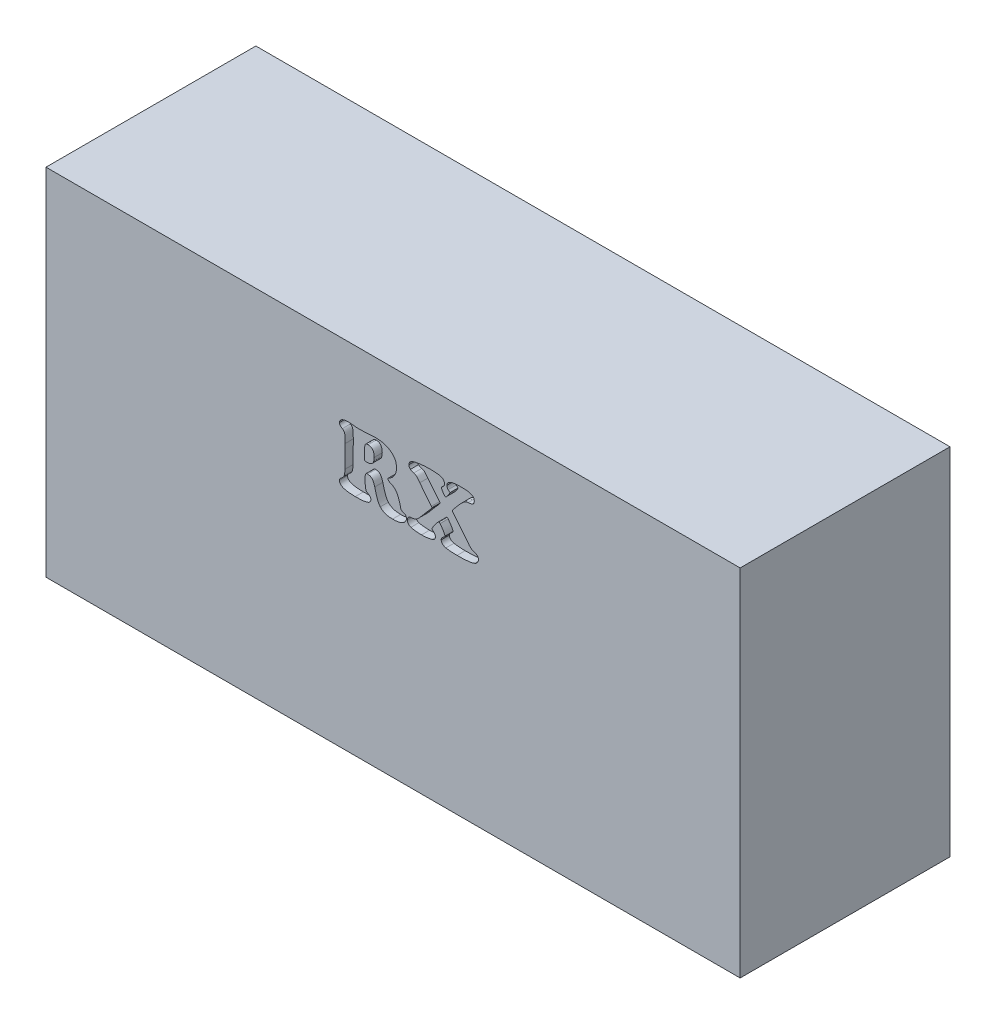
from build123d import *

# Parameters (mm, degrees)
SKICA1_W                 = 43
SKICA1_H                 = 22
P_IDAT_VYSUNUT_M1_DEPTH  = 13
ODEBRAT_VYSUNUT_M1_DEPTH = 0.5


with BuildPart() as part:
    # Skica1 → Přidat vysunutím1 (new body)
    with BuildSketch(Plane.XY):
        Rectangle(SKICA1_W, SKICA1_H)
    extrude(amount=P_IDAT_VYSUNUT_M1_DEPTH)

    # Skica2 → Odebrat vysunutím1 (cut)
    with BuildSketch(Plane.XY.offset(13)):
        with BuildLine():
            add(Edge.make_bspline(
                [(-1.572781919, 4.49421781), (-1.588608599, 4.493540747), (-1.617543428, 4.492302918), (-1.656940454, 4.481341999), (-1.687752348, 4.461780661), (-1.709226978, 4.430636779), (-1.719786113, 4.385275299), (-1.727988533, 4.323695248), (-1.733289869, 4.241782849), (-1.733575054, 4.180592882), (-1.733733056, 4.146691475)],
                knots=[0, 0, 0, 0, 4.7414e-05, 8.6683e-05, 0.000121329, 0.000154654, 0.000197222, 0.000259506, 0.000341375, 0.000443083, 0.000443083, 0.000443083, 0.000443083], degree=3))
            add(Edge.make_bspline(
                [(-1.733733056, 4.146691475), (-1.733034466, 4.093298054), (-1.731716762, 3.992585564), (-1.724299394, 3.85063852), (-1.710592094, 3.726999532), (-1.695749286, 3.651485893), (-1.688890948, 3.616593702)],
                knots=[0, 0, 0, 0, 0.000160182, 0.000302142, 0.000426297, 0.000532941, 0.000532941, 0.000532941, 0.000532941], degree=3))
            add(Edge.make_bspline(
                [(-1.688890948, 3.616593702), (-1.684127334, 3.600511281), (-1.675312966, 3.570753122), (-1.653586829, 3.537995344), (-1.629618789, 3.517112325), (-1.606051362, 3.499963972), (-1.575732208, 3.48158476), (-1.55359499, 3.468931701), (-1.541552594, 3.462048581)],
                knots=[0, 0, 0, 0, 5.0148e-05, 9.2791e-05, 0.000115468, 0.000145258, 0.000180143, 0.000221759, 0.000221759, 0.000221759, 0.000221759], degree=3))
            add(Edge.make_bspline(
                [(-1.541552594, 3.462048581), (-1.516360635, 3.447497104), (-1.469149321, 3.420226725), (-1.415435726, 3.363412764), (-1.380687731, 3.298945298), (-1.37689821, 3.25239437), (-1.374996194, 3.229029771)],
                knots=[0, 0, 0, 0, 8.6844e-05, 0.000162751, 0.000231866, 0.000301513, 0.000301513, 0.000301513, 0.000301513], degree=3))
            add(Edge.make_bspline(
                [(-1.374996194, 3.229029771), (-1.375517318, 3.214817089), (-1.376535491, 3.18704835), (-1.38732285, 3.147006906), (-1.405339221, 3.110569782), (-1.429759017, 3.076990366), (-1.461609338, 3.047437747), (-1.499822521, 3.020699236), (-1.545172981, 2.997579532), (-1.597937822, 2.977810691), (-1.658576936, 2.959850311), (-1.728679384, 2.946268776), (-1.807671832, 2.933293435), (-1.896391907, 2.923077064), (-1.994412239, 2.915200674), (-2.102307463, 2.910001943), (-2.219485575, 2.905475974), (-2.300927191, 2.905508927), (-2.34310527, 2.905525994)],
                knots=[0, 0, 0, 0, 4.2561e-05, 8.3155e-05, 0.000123264, 0.000163945, 0.000206993, 0.000252979, 0.000303477, 0.000359243, 0.00042183, 0.00049297, 0.000573273, 0.000661969, 0.000760787, 0.000868234, 0.000986012, 0.001112534, 0.001112534, 0.001112534, 0.001112534], degree=3))
            add(Edge.make_bspline(
                [(-2.34310527, 2.905525994), (-2.382609986, 2.905918633), (-2.459237712, 2.906680241), (-2.57038312, 2.910097039), (-2.673698089, 2.918424239), (-2.769278269, 2.928869425), (-2.857429638, 2.940839528), (-2.937663492, 2.958251482), (-3.010703665, 2.976702377), (-3.075758847, 2.999582357), (-3.134077672, 3.023557981), (-3.183862685, 3.052891425), (-3.226653128, 3.083832102), (-3.26235142, 3.117718096), (-3.288688834, 3.15595845), (-3.30850504, 3.196295566), (-3.320135137, 3.24014002), (-3.321646486, 3.270332959), (-3.322424873, 3.285883157)],
                knots=[0, 0, 0, 0, 0.000118522, 0.000229899, 0.000333506, 0.000429362, 0.000518372, 0.000600193, 0.000675553, 0.00074418, 0.000806951, 0.00086436, 0.000917052, 0.000965184, 0.001011169, 0.00105558, 0.001099476, 0.001146092, 0.001146092, 0.001146092, 0.001146092], degree=3))
            add(Edge.make_bspline(
                [(-3.322424873, 3.285883157), (-3.321596194, 3.30584984), (-3.32007455, 3.34251323), (-3.301579911, 3.385793067), (-3.276751733, 3.414974707), (-3.249969088, 3.440421886), (-3.214646805, 3.469729514), (-3.187976791, 3.490175578), (-3.173485015, 3.501285425)],
                knots=[0, 0, 0, 0, 5.9601e-05, 0.000109441, 0.00013733, 0.000174138, 0.000220173, 0.000274952, 0.000274952, 0.000274952, 0.000274952], degree=3))
            add(Edge.make_bspline(
                [(-3.173485015, 3.501285425), (-3.156435183, 3.514351204), (-3.123441467, 3.539635243), (-3.083373184, 3.585653009), (-3.050322818, 3.633897985), (-3.026090415, 3.689301558), (-3.008381901, 3.756226241), (-2.995013131, 3.839683106), (-2.982903598, 3.94225491), (-2.978230976, 4.017201175), (-2.97569929, 4.057808012)],
                knots=[0, 0, 0, 0, 6.4285e-05, 0.0001244, 0.000182143, 0.000239137, 0.000304804, 0.00038932, 0.000492518, 0.00061455, 0.00061455, 0.00061455, 0.00061455], degree=3))
            add(Edge.make_bspline(
                [(-2.97569929, 4.057808012), (-2.975153864, 4.067149197), (-2.973907628, 4.088492754), (-2.972111759, 4.124518151), (-2.971970378, 4.168325403), (-2.969657726, 4.219810685), (-2.969365986, 4.27908477), (-2.968414464, 4.346077334), (-2.967661675, 4.420815413), (-2.966853426, 4.503292582), (-2.966045658, 4.593777662), (-2.965310143, 4.692003488), (-2.96425829, 4.797967828), (-2.964496094, 4.911676549), (-2.964739016, 5.033392355), (-2.963382943, 5.162843905), (-2.963771318, 5.300041419), (-2.963716301, 5.393996142), (-2.963688011, 5.442308088)],
                knots=[0, 0, 0, 0, 2.8072e-05, 6.4141e-05, 0.00010819, 0.000159463, 0.000218724, 0.000285992, 0.000360466, 0.000442948, 0.000533436, 0.000631932, 0.000737634, 0.000851341, 0.000973055, 0.00110278, 0.001239708, 0.001384644, 0.001384644, 0.001384644, 0.001384644], degree=3))
            add(Edge.make_bspline(
                [(-2.963688011, 5.442308088), (-2.963882893, 5.472470791), (-2.964257163, 5.530397904), (-2.965936081, 5.613411296), (-2.967984996, 5.688985236), (-2.972109919, 5.756784366), (-2.976918547, 5.817115332), (-2.982113324, 5.870081105), (-2.98934816, 5.915475013), (-2.999459431, 5.964984551), (-3.017303156, 6.018419543), (-3.048650643, 6.074275169), (-3.091253269, 6.120305538), (-3.125713973, 6.142837341), (-3.143056442, 6.154176548)],
                knots=[0, 0, 0, 0, 9.0489e-05, 0.000173782, 0.000249091, 0.000317273, 0.000377521, 0.000430667, 0.000476875, 0.000515353, 0.000582205, 0.000644976, 0.000706169, 0.000768164, 0.000768164, 0.000768164, 0.000768164], degree=3))
            add(Edge.make_bspline(
                [(-3.143056442, 6.154176548), (-3.159462519, 6.163309752), (-3.189844001, 6.180223014), (-3.230396045, 6.20678317), (-3.262533308, 6.231758562), (-3.294010195, 6.264410017), (-3.318574436, 6.315232822), (-3.321091256, 6.359130355), (-3.322424873, 6.382390847)],
                knots=[0, 0, 0, 0, 5.6315e-05, 0.000104287, 0.000145305, 0.000178165, 0.000239761, 0.000309187, 0.000309187, 0.000309187, 0.000309187], degree=3))
            add(Edge.make_bspline(
                [(-3.322424873, 6.382390847), (-3.321546543, 6.398789984), (-3.319811662, 6.431181643), (-3.30459675, 6.477457004), (-3.280696747, 6.520648908), (-3.246554827, 6.559367766), (-3.20459378, 6.59491422), (-3.154559422, 6.625216946), (-3.09706405, 6.650122544), (-3.05566679, 6.662057258), (-3.03415418, 6.668259284)],
                knots=[0, 0, 0, 0, 4.9082e-05, 9.6946e-05, 0.000144623, 0.000196301, 0.000250846, 0.000309076, 0.000371112, 0.000438227, 0.000438227, 0.000438227, 0.000438227], degree=3))
            add(Edge.make_bspline(
                [(-3.03415418, 6.668259284), (-3.013121714, 6.672832128), (-2.967879799, 6.682668552), (-2.893974255, 6.691734924), (-2.809765609, 6.697298277), (-2.750164784, 6.697683476), (-2.718657922, 6.697887105)],
                knots=[0, 0, 0, 0, 6.4544e-05, 0.000138837, 0.000223103, 0.000317605, 0.000317605, 0.000317605, 0.000317605], degree=3))
            add(Edge.make_bspline(
                [(-2.718657922, 6.697887105), (-2.709849012, 6.69764209), (-2.689554689, 6.697077616), (-2.65483034, 6.695514252), (-2.61211688, 6.692217974), (-2.561137182, 6.687325614), (-2.501941206, 6.680617548), (-2.434331859, 6.67386223), (-2.35861032, 6.664579864), (-2.305475459, 6.658601304), (-2.277443612, 6.655447253)],
                knots=[0, 0, 0, 0, 2.6437e-05, 6.0907e-05, 0.000104266, 0.000154941, 0.000214542, 0.000282987, 0.000358771, 0.000443397, 0.000443397, 0.000443397, 0.000443397], degree=3))
            add(Edge.make_bspline(
                [(-2.277443612, 6.655447253), (-2.264643709, 6.653961393), (-2.23591015, 6.650625898), (-2.187767471, 6.648880131), (-2.130118656, 6.647147599), (-2.08846873, 6.646816981), (-2.066045104, 6.646638982)],
                knots=[0, 0, 0, 0, 3.8644e-05, 8.6749e-05, 0.000144426, 0.000211693, 0.000211693, 0.000211693, 0.000211693], degree=3))
            add(Edge.make_bspline(
                [(-2.066045104, 6.646638982), (-2.02253452, 6.64729049), (-1.929080381, 6.648689831), (-1.778740937, 6.654266235), (-1.608489259, 6.665270252), (-1.488162008, 6.674039753), (-1.424642813, 6.678669059)],
                knots=[0, 0, 0, 0, 0.000130545, 0.00028039, 0.000451268, 0.000642332, 0.000642332, 0.000642332, 0.000642332], degree=3))
            add(Edge.make_bspline(
                [(-1.424642813, 6.678669059), (-1.385419424, 6.681823935), (-1.313415009, 6.687615506), (-1.214849062, 6.692506407), (-1.135620612, 6.697562105), (-1.089133151, 6.697789259), (-1.069108959, 6.697887105)],
                knots=[0, 0, 0, 0, 0.00011804, 0.000216691, 0.000296067, 0.000356129, 0.000356129, 0.000356129, 0.000356129], degree=3))
            add(Edge.make_bspline(
                [(-1.069108959, 6.697887105), (-1.022358419, 6.697307779), (-0.93078224, 6.696172979), (-0.79681654, 6.681722157), (-0.669045298, 6.660674526), (-0.547451317, 6.630120263), (-0.432132382, 6.590779078), (-0.322390224, 6.54377003), (-0.21942755, 6.486630853), (-0.155367287, 6.442188993), (-0.123420937, 6.420026187)],
                knots=[0, 0, 0, 0, 0.000140189, 0.000274605, 0.000403748, 0.000528431, 0.000650232, 0.000768941, 0.000886149, 0.001002746, 0.001002746, 0.001002746, 0.001002746], degree=3))
            add(Edge.make_bspline(
                [(-0.123420937, 6.420026187), (-0.096382229, 6.398823417), (-0.043305051, 6.357202228), (0.024941988, 6.283681429), (0.083977095, 6.205448186), (0.131414878, 6.120411383), (0.168794573, 6.02963532), (0.195071147, 5.932539107), (0.210224339, 5.829279493), (0.212521801, 5.758654853), (0.213695623, 5.722571262)],
                knots=[0, 0, 0, 0, 0.000102936, 0.000202065, 0.000299917, 0.00039636, 0.000493314, 0.000593744, 0.000697363, 0.00080561, 0.00080561, 0.00080561, 0.00080561], degree=3))
            add(Edge.make_bspline(
                [(0.213695623, 5.722571262), (0.21243883, 5.681890205), (0.209971214, 5.60201603), (0.18659304, 5.485078707), (0.148760526, 5.373959551), (0.096983349, 5.269346658), (0.032174638, 5.173804951), (-0.044480597, 5.089774048), (-0.132447886, 5.017758781), (-0.198840792, 4.981662197), (-0.232323199, 4.963458438)],
                knots=[0, 0, 0, 0, 0.000121927, 0.000239395, 0.000356132, 0.000473234, 0.000588503, 0.000701296, 0.000813472, 0.000927598, 0.000927598, 0.000927598, 0.000927598], degree=3))
            add(Edge.make_bspline(
                [(-0.232323199, 4.963458438), (-0.245210792, 4.956489619), (-0.268937127, 4.943659873), (-0.29693698, 4.918814526), (-0.31527893, 4.890999309), (-0.317649335, 4.870803423), (-0.318804407, 4.860962192)],
                knots=[0, 0, 0, 0, 4.3808e-05, 8.0651e-05, 0.00011155, 0.000140917, 0.000140917, 0.000140917, 0.000140917], degree=3))
            add(Edge.make_bspline(
                [(-0.318804407, 4.860962192), (-0.317307522, 4.847939216), (-0.314209448, 4.820985807), (-0.284577291, 4.787030779), (-0.243803695, 4.755795715), (-0.208581244, 4.742051815), (-0.189082595, 4.734443388)],
                knots=[0, 0, 0, 0, 3.8478e-05, 7.9637e-05, 0.000129925, 0.000192286, 0.000192286, 0.000192286, 0.000192286], degree=3))
            add(Edge.make_bspline(
                [(-0.189082595, 4.734443388), (-0.145479525, 4.716225681), (-0.061165474, 4.680998606), (0.051282674, 4.609032346), (0.145778077, 4.52401873), (0.221057556, 4.422292255), (0.283880102, 4.303748673), (0.341868984, 4.166102359), (0.396214667, 4.006625008), (0.426138602, 3.891743284), (0.441909921, 3.831195218)],
                knots=[0, 0, 0, 0, 0.000141554, 0.00027372, 0.000398416, 0.000520771, 0.000651205, 0.000800089, 0.000968485, 0.001156142, 0.001156142, 0.001156142, 0.001156142], degree=3))
            add(Edge.make_bspline(
                [(0.441909921, 3.831195218), (0.445798622, 3.805780473), (0.452849494, 3.759699252), (0.467589547, 3.69768654), (0.485460275, 3.650630334), (0.506370199, 3.613045139), (0.540841806, 3.588082465), (0.584680655, 3.56385323), (0.643786077, 3.541529193), (0.688195687, 3.527952988), (0.712564071, 3.520503471)],
                knots=[0, 0, 0, 0, 7.7143e-05, 0.000139873, 0.00019058, 0.000228352, 0.000266495, 0.00031596, 0.000378859, 0.000455338, 0.000455338, 0.000455338, 0.000455338], degree=3))
            add(Edge.make_bspline(
                [(0.712564071, 3.520503471), (0.72835024, 3.511876981), (0.762396555, 3.493272075), (0.797712911, 3.44218925), (0.825036637, 3.381053225), (0.827441309, 3.335064768), (0.8286731, 3.311507219)],
                knots=[0, 0, 0, 0, 5.3309e-05, 0.000114972, 0.000181742, 0.000251866, 0.000251866, 0.000251866, 0.000251866], degree=3))
            add(Edge.make_bspline(
                [(0.8286731, 3.311507219), (0.827906417, 3.295679978), (0.82636403, 3.263839247), (0.813294487, 3.216007447), (0.792567647, 3.168258185), (0.763433974, 3.12176043), (0.729642685, 3.076714755), (0.689153031, 3.037090477), (0.644886273, 3.000761047), (0.611707592, 2.981680771), (0.594853538, 2.971988403)],
                knots=[0, 0, 0, 0, 4.7414e-05, 9.5385e-05, 0.000147747, 0.000203092, 0.000259629, 0.000316251, 0.000372651, 0.000430881, 0.000430881, 0.000430881, 0.000430881], degree=3))
            add(Edge.make_bspline(
                [(0.594853538, 2.971988403), (0.574964736, 2.962605957), (0.534213726, 2.943381864), (0.46877262, 2.919677075), (0.398388461, 2.898398487), (0.322118438, 2.883144056), (0.240923043, 2.870198151), (0.154628615, 2.860639542), (0.062965353, 2.854956008), (0.000170222, 2.854508232), (-0.032135218, 2.85427787)],
                knots=[0, 0, 0, 0, 6.5939e-05, 0.000135106, 0.000208583, 0.000286322, 0.000368207, 0.00045522, 0.000546678, 0.000643582, 0.000643582, 0.000643582, 0.000643582], degree=3))
            add(Edge.make_bspline(
                [(-0.032135218, 2.85427787), (-0.074893594, 2.854797646), (-0.157444107, 2.855801138), (-0.276143794, 2.870447472), (-0.386145523, 2.890103042), (-0.486089024, 2.920795694), (-0.577523587, 2.958905988), (-0.658116182, 3.007873816), (-0.732257226, 3.062231616), (-0.772215739, 3.107344935), (-0.792048794, 3.129736532)],
                knots=[0, 0, 0, 0, 0.000128183, 0.000247473, 0.000358348, 0.000462965, 0.000560538, 0.000654609, 0.000745419, 0.00083491, 0.00083491, 0.00083491, 0.00083491], degree=3))
            add(Edge.make_bspline(
                [(-0.792048794, 3.129736532), (-0.809052776, 3.151303385), (-0.843958212, 3.19557539), (-0.888989589, 3.270218649), (-0.931852412, 3.351681326), (-0.962732176, 3.426686501), (-0.986581787, 3.492570883), (-1.006073482, 3.549081561), (-1.025833814, 3.612170612), (-1.046655839, 3.681842165), (-1.068211047, 3.757938625), (-1.090742109, 3.840659333), (-1.113704726, 3.929881702), (-1.129197886, 3.99160439), (-1.137172873, 4.023375679)],
                knots=[0, 0, 0, 0, 8.2318e-05, 0.000168981, 0.000261025, 0.000358286, 0.00041199, 0.000471246, 0.000537597, 0.000610307, 0.000689391, 0.000774862, 0.000867504, 0.000965775, 0.000965775, 0.000965775, 0.000965775], degree=3))
            add(Edge.make_bspline(
                [(-1.137172873, 4.023375679), (-1.147668836, 4.062832657), (-1.167204719, 4.136272976), (-1.204846826, 4.235608765), (-1.245765624, 4.31711586), (-1.293054181, 4.381643627), (-1.349124736, 4.430341311), (-1.414505695, 4.465129999), (-1.490368, 4.486914269), (-1.544341779, 4.491697438), (-1.572781919, 4.49421781)],
                knots=[0, 0, 0, 0, 0.000122421, 0.000227859, 0.000318113, 0.000395306, 0.000466266, 0.000538994, 0.00061577, 0.000701286, 0.000701286, 0.000701286, 0.000701286], degree=3))
        make_face()
        with BuildLine():
            Line((-1.754552606, 5.874714127), (-1.784981179, 5.284559959))
            add(Edge.make_bspline(
                [(-1.784981179, 5.284559959), (-1.784981179, 5.281356952), (-1.784981179, 5.27361635), (-1.784981179, 5.265875748), (-1.784981179, 5.261338153)],
                knots=[0, 0, 0, 0, 9.609e-06, 2.3222e-05, 2.3222e-05, 2.3222e-05, 2.3222e-05], degree=3))
            add(Edge.make_bspline(
                [(-1.784981179, 5.261338153), (-1.784818916, 5.247430515), (-1.784520807, 5.221879549), (-1.778982836, 5.187417857), (-1.770732899, 5.159837072), (-1.757283306, 5.138693451), (-1.736869313, 5.123830458), (-1.709508569, 5.116531991), (-1.676190395, 5.109176288), (-1.651319678, 5.109188547), (-1.637642825, 5.109195288)],
                knots=[0, 0, 0, 0, 4.167e-05, 7.6555e-05, 0.00010441, 0.000127507, 0.000150409, 0.000178263, 0.000211713, 0.000252583, 0.000252583, 0.000252583, 0.000252583], degree=3))
            add(Edge.make_bspline(
                [(-1.637642825, 5.109195288), (-1.599350001, 5.110338381), (-1.527924247, 5.112470537), (-1.4287725, 5.134064682), (-1.345578659, 5.169672202), (-1.278267664, 5.222010447), (-1.228025246, 5.291529827), (-1.19400846, 5.377585732), (-1.173532791, 5.480060028), (-1.171234342, 5.554039791), (-1.170003702, 5.593650202)],
                knots=[0, 0, 0, 0, 0.000114734, 0.000214008, 0.000302548, 0.000384087, 0.000466569, 0.000556684, 0.000659705, 0.000778435, 0.000778435, 0.000778435, 0.000778435], degree=3))
            add(Edge.make_bspline(
                [(-1.170003702, 5.593650202), (-1.170759382, 5.631915277), (-1.172180716, 5.703886852), (-1.190881475, 5.80417436), (-1.219685986, 5.89009267), (-1.261772602, 5.961141447), (-1.316948561, 6.016746121), (-1.384555501, 6.056020244), (-1.464344065, 6.078673415), (-1.521113865, 6.081443465), (-1.551161617, 6.082909627)],
                knots=[0, 0, 0, 0, 0.000114645, 0.000215631, 0.000304778, 0.000385252, 0.000461126, 0.00053721, 0.000617285, 0.000707326, 0.000707326, 0.000707326, 0.000707326], degree=3))
            add(Edge.make_bspline(
                [(-1.551161617, 6.082909627), (-1.567998079, 6.082221307), (-1.599219497, 6.08094489), (-1.64257547, 6.073688313), (-1.677892302, 6.059226987), (-1.706423907, 6.03861629), (-1.726056625, 6.008811442), (-1.74154712, 5.972058109), (-1.750092648, 5.926008441), (-1.752995732, 5.892619848), (-1.754552606, 5.874714127)],
                knots=[0, 0, 0, 0, 5.0549e-05, 9.3738e-05, 0.000131065, 0.000164217, 0.000197542, 0.000236656, 0.000283299, 0.000337242, 0.000337242, 0.000337242, 0.000337242], degree=3))
        make_face(mode=Mode.SUBTRACT)
        with BuildLine():
            Line((3.701771003, 5.097984761), (4.726733465, 3.815980931))
            add(Edge.make_bspline(
                [(4.726733465, 3.815980931), (4.741016159, 3.800905639), (4.767504809, 3.772947038), (4.806143723, 3.735973845), (4.83940264, 3.706453329), (4.878631726, 3.675030378), (4.937661149, 3.646833964), (4.988330415, 3.631536336), (5.016605662, 3.622999717)],
                knots=[0, 0, 0, 0, 6.2294e-05, 0.000115531, 0.000160351, 0.000195748, 0.00026594, 0.000354567, 0.000354567, 0.000354567, 0.000354567], degree=3))
            add(Edge.make_bspline(
                [(5.016605662, 3.622999717), (5.039655012, 3.614455931), (5.082854953, 3.598442853), (5.141877498, 3.572150816), (5.188992914, 3.542076033), (5.226654119, 3.510728425), (5.254066996, 3.474706922), (5.273902926, 3.43461485), (5.2850099, 3.388695381), (5.286487541, 3.356408078), (5.287259812, 3.339533536)],
                knots=[0, 0, 0, 0, 7.3761e-05, 0.000138245, 0.000193334, 0.000241017, 0.000284421, 0.000328111, 0.000374333, 0.000424939, 0.000424939, 0.000424939, 0.000424939], degree=3))
            add(Edge.make_bspline(
                [(5.287259812, 3.339533536), (5.286581583, 3.322894836), (5.285236796, 3.289903731), (5.271437375, 3.241408088), (5.249533924, 3.194842227), (5.220033122, 3.150405943), (5.184140297, 3.109777125), (5.143251981, 3.074418551), (5.097379099, 3.044789378), (5.064076781, 3.030002829), (5.047034235, 3.022435774)],
                knots=[0, 0, 0, 0, 4.9808e-05, 9.8759e-05, 0.000149988, 0.000203734, 0.000258197, 0.000312133, 0.000365442, 0.000421317, 0.000421317, 0.000421317, 0.000421317], degree=3))
            add(Edge.make_bspline(
                [(5.047034235, 3.022435774), (5.01835906, 3.012070486), (4.958552846, 2.990452181), (4.861597072, 2.966550072), (4.755106161, 2.945298758), (4.635726602, 2.930462891), (4.499716503, 2.919691598), (4.342479202, 2.910648053), (4.161692832, 2.906409096), (4.033283653, 2.90583193), (3.965218386, 2.905525994)],
                knots=[0, 0, 0, 0, 9.1416e-05, 0.00019066, 0.000299176, 0.000417072, 0.000551267, 0.000708461, 0.000889495, 0.001093693, 0.001093693, 0.001093693, 0.001093693], degree=3))
            add(Edge.make_bspline(
                [(3.965218386, 2.905525994), (3.927850093, 2.90569844), (3.855774319, 2.906031055), (3.751094107, 2.908045408), (3.65397394, 2.913412012), (3.563643125, 2.918270664), (3.480962944, 2.926791306), (3.405001913, 2.93507309), (3.336584436, 2.946076266), (3.293617951, 2.955524408), (3.273368723, 2.959977124)],
                knots=[0, 0, 0, 0, 0.000112108, 0.000216234, 0.000314043, 0.000403903, 0.000487565, 0.000563349, 0.00063312, 0.000695312, 0.000695312, 0.000695312, 0.000695312], degree=3))
            add(Edge.make_bspline(
                [(3.273368723, 2.959977124), (3.251846984, 2.96616449), (3.210432156, 2.978070994), (3.152848946, 3.003263598), (3.101890283, 3.033236888), (3.059409846, 3.069718642), (3.024378318, 3.109152562), (3.000191125, 3.152757195), (2.983552031, 3.198216234), (2.981914303, 3.229954036), (2.981094271, 3.245845561)],
                knots=[0, 0, 0, 0, 6.7115e-05, 0.000129152, 0.000188065, 0.000243739, 0.000296546, 0.000345313, 0.000392666, 0.000440154, 0.000440154, 0.000440154, 0.000440154], degree=3))
            add(Edge.make_bspline(
                [(2.981094271, 3.245845561), (2.982368969, 3.265566853), (2.984902122, 3.304758129), (3.0087755, 3.359426273), (3.046481107, 3.408228153), (3.080177429, 3.43295311), (3.098004052, 3.446033542)],
                knots=[0, 0, 0, 0, 5.8897e-05, 0.000117044, 0.000175827, 0.000241859, 0.000241859, 0.000241859, 0.000241859], degree=3))
            add(Edge.make_bspline(
                [(3.098004052, 3.446033542), (3.115109084, 3.457464353), (3.145638228, 3.47786612), (3.182034861, 3.508538464), (3.207608288, 3.534651624), (3.212227489, 3.553604938), (3.214113081, 3.561341819)],
                knots=[0, 0, 0, 0, 6.1533e-05, 0.000109824, 0.000143967, 0.000167518, 0.000167518, 0.000167518, 0.000167518], degree=3))
            add(Edge.make_bspline(
                [(3.214113081, 3.561341819), (3.212857435, 3.572356773), (3.209915147, 3.598167521), (3.194905931, 3.640966814), (3.170394602, 3.69241944), (3.137033481, 3.753792311), (3.094599454, 3.824418544), (3.043403493, 3.904947456), (2.980928271, 3.993478449), (2.936536977, 4.05595434), (2.913030358, 4.089037337)],
                knots=[0, 0, 0, 0, 3.3181e-05, 7.775e-05, 0.000135075, 0.000204223, 0.00028717, 0.00038224, 0.000490416, 0.000612172, 0.000612172, 0.000612172, 0.000612172], degree=3))
            add(Edge.make_bspline(
                [(2.913030358, 4.089037337), (2.907119088, 4.096733119), (2.896357452, 4.110743512), (2.878724655, 4.126718399), (2.862400798, 4.137981515), (2.850963188, 4.139565756), (2.845767196, 4.14028546)],
                knots=[0, 0, 0, 0, 2.9016e-05, 5.2824e-05, 7.15e-05, 8.7048e-05, 8.7048e-05, 8.7048e-05, 8.7048e-05], degree=3))
            add(Edge.make_bspline(
                [(2.845767196, 4.14028546), (2.83459974, 4.137360322), (2.807211814, 4.130186491), (2.788679202, 4.108366323), (2.777703283, 4.095443352)],
                knots=[0, 0, 0, 0, 3.3935e-05, 8.3225e-05, 8.3225e-05, 8.3225e-05, 8.3225e-05], degree=3))
            add(Edge.make_bspline(
                [(2.777703283, 4.095443352), (2.732317165, 4.042428667), (2.643643776, 3.938850921), (2.547262775, 3.804262931), (2.482292124, 3.705030711), (2.449267836, 3.645466914), (2.425081894, 3.601453843), (2.420669932, 3.574826114), (2.418966421, 3.564544827)],
                knots=[0, 0, 0, 0, 0.000209255, 0.000408834, 0.000496351, 0.000564485, 0.000613925, 0.00064502, 0.00064502, 0.00064502, 0.00064502], degree=3))
            add(Edge.make_bspline(
                [(2.418966421, 3.564544827), (2.420558121, 3.556042387), (2.424300878, 3.536049563), (2.447255303, 3.506888262), (2.479315952, 3.472256271), (2.50697001, 3.449184052), (2.522263419, 3.436424519)],
                knots=[0, 0, 0, 0, 2.5637e-05, 6.0282e-05, 0.000108441, 0.000168026, 0.000168026, 0.000168026, 0.000168026], degree=3))
            add(Edge.make_bspline(
                [(2.522263419, 3.436424519), (2.537642421, 3.422923362), (2.567261645, 3.396920778), (2.599486898, 3.347968633), (2.618780387, 3.293418463), (2.621145573, 3.255079363), (2.622357409, 3.235435786)],
                knots=[0, 0, 0, 0, 6.1162e-05, 0.000117795, 0.000173762, 0.000232567, 0.000232567, 0.000232567, 0.000232567], degree=3))
            add(Edge.make_bspline(
                [(2.622357409, 3.235435786), (2.621764338, 3.220971841), (2.620608076, 3.192772678), (2.610893846, 3.151916348), (2.593975051, 3.115154466), (2.570868555, 3.081822788), (2.540569805, 3.05305748), (2.504272182, 3.027285772), (2.461335506, 3.005513064), (2.429806119, 2.995058035), (2.413361157, 2.989604946)],
                knots=[0, 0, 0, 0, 4.3359e-05, 8.4534e-05, 0.000125025, 0.000164123, 0.00020546, 0.000249676, 0.000297306, 0.000349231, 0.000349231, 0.000349231, 0.000349231], degree=3))
            add(Edge.make_bspline(
                [(2.413361157, 2.989604946), (2.365775584, 2.976487793), (2.267268466, 2.949333914), (2.110103726, 2.923859331), (1.940148706, 2.908878478), (1.822439924, 2.906668972), (1.761549091, 2.905525994)],
                knots=[0, 0, 0, 0, 0.000147992, 0.000306359, 0.000476798, 0.000659456, 0.000659456, 0.000659456, 0.000659456], degree=3))
            add(Edge.make_bspline(
                [(1.761549091, 2.905525994), (1.726843582, 2.905508488), (1.659541909, 2.90547454), (1.561586188, 2.910100286), (1.469964855, 2.915214704), (1.384478757, 2.923171673), (1.305249818, 2.933897635), (1.231791472, 2.945033595), (1.164874012, 2.960649993), (1.122772475, 2.972633031), (1.102530258, 2.978394419)],
                knots=[0, 0, 0, 0, 0.000104101, 0.000201875, 0.000294131, 0.000379388, 0.000459343, 0.000533985, 0.000602167, 0.000665304, 0.000665304, 0.000665304, 0.000665304], degree=3))
            add(Edge.make_bspline(
                [(1.102530258, 2.978394419), (1.087367423, 2.984069756), (1.057041754, 2.995420429), (1.015454353, 3.020780284), (0.976906188, 3.051708265), (0.943158721, 3.088719724), (0.915680102, 3.129642512), (0.894852558, 3.172038502), (0.882288004, 3.215768834), (0.880706275, 3.245501852), (0.879921223, 3.260259096)],
                knots=[0, 0, 0, 0, 4.8477e-05, 9.6954e-05, 0.000145351, 0.000196361, 0.000246554, 0.000292755, 0.000337633, 0.000381856, 0.000381856, 0.000381856, 0.000381856], degree=3))
            add(Edge.make_bspline(
                [(0.879921223, 3.260259096), (0.8807075, 3.279056512), (0.882230209, 3.315459677), (0.897819732, 3.366665623), (0.923245555, 3.411357698), (0.958808402, 3.448889017), (1.003618231, 3.479851761), (1.057854019, 3.501538202), (1.120194113, 3.516434962), (1.164625641, 3.519092697), (1.188210714, 3.520503471)],
                knots=[0, 0, 0, 0, 5.6258e-05, 0.00010895, 0.000158809, 0.000209231, 0.000262762, 0.000320909, 0.000383449, 0.000454206, 0.000454206, 0.000454206, 0.000454206], degree=3))
            add(Edge.make_bspline(
                [(1.188210714, 3.520503471), (1.217153524, 3.522574469), (1.273319258, 3.5265934), (1.353824107, 3.546833754), (1.427027262, 3.579385579), (1.483480349, 3.616873841), (1.528875274, 3.655095676), (1.568268908, 3.693508797), (1.613345108, 3.74053149), (1.664843558, 3.795845553), (1.721514115, 3.860319676), (1.784869225, 3.932659409), (1.852758802, 4.014945895), (1.900087344, 4.072482646), (1.924902484, 4.10265012)],
                knots=[0, 0, 0, 0, 8.6929e-05, 0.000168692, 0.000247557, 0.000326177, 0.000371084, 0.000425452, 0.000491143, 0.000566503, 0.000652154, 0.00074865, 0.000854969, 0.000972159, 0.000972159, 0.000972159, 0.000972159], degree=3))
            Line((1.924902484, 4.10265012), (2.375725817, 4.619935862))
            add(Edge.make_bspline(
                [(2.375725817, 4.619935862), (2.386401969, 4.631784897), (2.403991587, 4.651306913), (2.410717563, 4.676497358), (2.413361157, 4.686398272)],
                knots=[0, 0, 0, 0, 4.6924e-05, 7.7311e-05, 7.7311e-05, 7.7311e-05, 7.7311e-05], degree=3))
            add(Edge.make_bspline(
                [(2.413361157, 4.686398272), (2.4107877, 4.694340045), (2.403418371, 4.717082038), (2.387128091, 4.734875131), (2.376526569, 4.746454666)],
                knots=[0, 0, 0, 0, 2.4836e-05, 7.1121e-05, 7.1121e-05, 7.1121e-05, 7.1121e-05], degree=3))
            Line((2.376526569, 4.746454666), (1.655049085, 5.644097573))
            add(Edge.make_bspline(
                [(1.655049085, 5.644097573), (1.642191805, 5.66061106), (1.617757024, 5.691994324), (1.583523588, 5.737411156), (1.551508623, 5.776771238), (1.523813766, 5.811710748), (1.498235291, 5.840205225), (1.478141387, 5.865600239), (1.459764858, 5.884429397), (1.439788447, 5.903552533), (1.413804793, 5.923929906), (1.376372427, 5.944441508), (1.331351512, 5.963321424), (1.298525081, 5.974486161), (1.281097937, 5.980413381)],
                knots=[0, 0, 0, 0, 6.2786e-05, 0.000119323, 0.000170596, 0.000214993, 0.000253035, 0.000285433, 0.000312051, 0.000331877, 0.000368397, 0.000410708, 0.000459495, 0.000514706, 0.000514706, 0.000514706, 0.000514706], degree=3))
            add(Edge.make_bspline(
                [(1.281097937, 5.980413381), (1.256637021, 5.988258307), (1.211761946, 6.002650314), (1.153301773, 6.028027702), (1.106540948, 6.048976815), (1.083083307, 6.067055683), (1.072902437, 6.074902108)],
                knots=[0, 0, 0, 0, 7.6981e-05, 0.000141226, 0.000191361, 0.000229805, 0.000229805, 0.000229805, 0.000229805], degree=3))
            add(Edge.make_bspline(
                [(1.072902437, 6.074902108), (1.05924284, 6.089107538), (1.032607905, 6.116806796), (1.002946296, 6.165893781), (0.985614355, 6.219764965), (0.983488624, 6.257085201), (0.982417469, 6.275890841)],
                knots=[0, 0, 0, 0, 5.8984e-05, 0.000115014, 0.000170475, 0.000226807, 0.000226807, 0.000226807, 0.000226807], degree=3))
            add(Edge.make_bspline(
                [(0.982417469, 6.275890841), (0.983269345, 6.296344716), (0.984933034, 6.336290549), (1.004668516, 6.392729789), (1.034769241, 6.443776717), (1.07778685, 6.488421102), (1.132556667, 6.526991505), (1.19916372, 6.559542479), (1.277436079, 6.586763451), (1.334315699, 6.599218328), (1.364376137, 6.605800633)],
                knots=[0, 0, 0, 0, 6.1115e-05, 0.000119355, 0.000177171, 0.00023778, 0.000303777, 0.000377189, 0.000459495, 0.000551749, 0.000551749, 0.000551749, 0.000551749], degree=3))
            add(Edge.make_bspline(
                [(1.364376137, 6.605800633), (1.433621313, 6.620045963), (1.575661713, 6.649266949), (1.797265872, 6.676767348), (2.031620572, 6.695177573), (2.192314643, 6.696967815), (2.274831075, 6.697887105)],
                knots=[0, 0, 0, 0, 0.00021201, 0.00043489, 0.000669372, 0.000916868, 0.000916868, 0.000916868, 0.000916868], degree=3))
            add(Edge.make_bspline(
                [(2.274831075, 6.697887105), (2.317542287, 6.697901144), (2.399516351, 6.697928089), (2.517238581, 6.6935054), (2.624280839, 6.687947848), (2.720540492, 6.681523273), (2.805666764, 6.670709571), (2.880287565, 6.659066271), (2.944512092, 6.645483661), (2.98278678, 6.632544758), (3.000312317, 6.626620184)],
                knots=[0, 0, 0, 0, 0.000128123, 0.000245901, 0.000353348, 0.000449709, 0.000535224, 0.000610657, 0.000676318, 0.000731779, 0.000731779, 0.000731779, 0.000731779], degree=3))
            add(Edge.make_bspline(
                [(3.000312317, 6.626620184), (3.013909026, 6.621236663), (3.040622365, 6.610659704), (3.076369134, 6.586283087), (3.108827671, 6.557729972), (3.135485778, 6.522983077), (3.158061052, 6.485836041), (3.174359708, 6.44588833), (3.184206959, 6.404222772), (3.185461009, 6.375769229), (3.186086764, 6.361571297)],
                knots=[0, 0, 0, 0, 4.3742e-05, 8.5939e-05, 0.000129031, 0.000172927, 0.000216735, 0.000259114, 0.000301848, 0.000344408, 0.000344408, 0.000344408, 0.000344408], degree=3))
            add(Edge.make_bspline(
                [(3.186086764, 6.361571297), (3.184945131, 6.340049998), (3.182757247, 6.298805483), (3.163565125, 6.241252882), (3.132976043, 6.190751474), (3.102853836, 6.166474819), (3.087594277, 6.154176548)],
                knots=[0, 0, 0, 0, 6.438e-05, 0.00012338, 0.000180251, 0.00023864, 0.00023864, 0.00023864, 0.00023864], degree=3))
            add(Edge.make_bspline(
                [(3.087594277, 6.154176548), (3.078544964, 6.147472347), (3.062290706, 6.135430349), (3.040377633, 6.119844163), (3.025332359, 6.107064458), (3.012673364, 6.095445777), (3.003815349, 6.078080431), (3.003113631, 6.063292819), (3.002714573, 6.05488331)],
                knots=[0, 0, 0, 0, 3.3793e-05, 6.0699e-05, 8.0589e-05, 9.3046e-05, 0.000112029, 0.000137058, 0.000137058, 0.000137058, 0.000137058], degree=3))
            add(Edge.make_bspline(
                [(3.002714573, 6.05488331), (3.004407, 6.043019998), (3.008495871, 6.01435847), (3.029557567, 5.967097388), (3.059489572, 5.907109939), (3.100795268, 5.841274598), (3.142569857, 5.777220398), (3.183154181, 5.729528922), (3.215073592, 5.694909193), (3.239123148, 5.688318723), (3.248545414, 5.685736673)],
                knots=[0, 0, 0, 0, 3.5811e-05, 8.6518e-05, 0.000153843, 0.000237202, 0.000319602, 0.000382142, 0.000426963, 0.000455835, 0.000455835, 0.000455835, 0.000455835], degree=3))
            add(Edge.make_bspline(
                [(3.248545414, 5.685736673), (3.257648451, 5.688694266), (3.281672709, 5.69649979), (3.315643099, 5.731698214), (3.359395535, 5.782514729), (3.407417134, 5.849141729), (3.454335466, 5.916442305), (3.489709093, 5.974079213), (3.514196799, 6.01409702), (3.520266995, 6.037160311), (3.522402572, 6.045274287)],
                knots=[0, 0, 0, 0, 2.8401e-05, 7.4955e-05, 0.000142528, 0.000231252, 0.000320539, 0.000388527, 0.000434735, 0.000459816, 0.000459816, 0.000459816, 0.000459816], degree=3))
            add(Edge.make_bspline(
                [(3.522402572, 6.045274287), (3.521957786, 6.050886051), (3.521080136, 6.061959177), (3.509319889, 6.073324474), (3.494461256, 6.084120608), (3.475493857, 6.101739293), (3.447304835, 6.12628431), (3.425753829, 6.145597607), (3.41350031, 6.156578804)],
                knots=[0, 0, 0, 0, 1.6332e-05, 3.2227e-05, 4.6484e-05, 7.202e-05, 0.000109459, 0.000158801, 0.000158801, 0.000158801, 0.000158801], degree=3))
            add(Edge.make_bspline(
                [(3.41350031, 6.156578804), (3.402200206, 6.168382021), (3.379374185, 6.192224321), (3.355769198, 6.238295343), (3.342407711, 6.292216799), (3.340721455, 6.330793507), (3.339831133, 6.351161522)],
                knots=[0, 0, 0, 0, 4.8813e-05, 9.8602e-05, 0.000153176, 0.000214223, 0.000214223, 0.000214223, 0.000214223], degree=3))
            add(Edge.make_bspline(
                [(3.339831133, 6.351161522), (3.340319203, 6.366187291), (3.341273242, 6.395558419), (3.352407397, 6.437282974), (3.368301307, 6.47656305), (3.39302766, 6.511339744), (3.42297385, 6.544198185), (3.460157191, 6.572970443), (3.504250697, 6.597497971), (3.554373635, 6.620436735), (3.612563536, 6.639119303), (3.678615406, 6.655905355), (3.752916821, 6.670308593), (3.835638973, 6.680793501), (3.926331412, 6.690909083), (4.025732054, 6.697031562), (4.133626927, 6.699807627), (4.208378724, 6.700652606), (4.247083063, 6.701090112)],
                knots=[0, 0, 0, 0, 4.4956e-05, 8.7877e-05, 0.000128778, 0.000171421, 0.000215053, 0.000261827, 0.000311686, 0.000366161, 0.000426934, 0.000494714, 0.000570566, 0.000653802, 0.000744796, 0.000844296, 0.000952445, 0.001068565, 0.001068565, 0.001068565, 0.001068565], degree=3))
            add(Edge.make_bspline(
                [(4.247083063, 6.701090112), (4.302349743, 6.700231128), (4.406584216, 6.69861106), (4.55298837, 6.68919272), (4.679541571, 6.670815681), (4.755691031, 6.650978711), (4.790793619, 6.64183447)],
                knots=[0, 0, 0, 0, 0.000165804, 0.000312711, 0.000439889, 0.00054865, 0.00054865, 0.00054865, 0.00054865], degree=3))
            add(Edge.make_bspline(
                [(4.790793619, 6.64183447), (4.809694286, 6.63541013), (4.846030432, 6.623059467), (4.895053339, 6.596961223), (4.937622706, 6.567664379), (4.971840468, 6.532411091), (4.998957279, 6.492768019), (5.017276914, 6.4476823), (5.028724794, 6.398439908), (5.030240261, 6.364038828), (5.031019196, 6.34635701)],
                knots=[0, 0, 0, 0, 5.9794e-05, 0.000114953, 0.000166057, 0.000214189, 0.000261494, 0.000309232, 0.000359347, 0.000412348, 0.000412348, 0.000412348, 0.000412348], degree=3))
            add(Edge.make_bspline(
                [(5.031019196, 6.34635701), (5.029489433, 6.323206933), (5.026545166, 6.27865099), (5.003520972, 6.216117616), (4.963375011, 6.163346988), (4.927206757, 6.138300842), (4.908504152, 6.125349479)],
                knots=[0, 0, 0, 0, 6.9329e-05, 0.000133434, 0.000196855, 0.000264768, 0.000264768, 0.000264768, 0.000264768], degree=3))
            add(Edge.make_bspline(
                [(4.908504152, 6.125349479), (4.897119564, 6.120783415), (4.868698254, 6.10938436), (4.814112503, 6.098748371), (4.74028865, 6.089602166), (4.684326325, 6.085308296), (4.653064288, 6.082909627)],
                knots=[0, 0, 0, 0, 3.6739e-05, 9.1717e-05, 0.00016601, 0.00026004, 0.00026004, 0.00026004, 0.00026004], degree=3))
            add(Edge.make_bspline(
                [(4.653064288, 6.082909627), (4.629941067, 6.079960352), (4.582732396, 6.073939074), (4.512568356, 6.049252319), (4.442319632, 6.012608157), (4.369544399, 5.964380569), (4.294222305, 5.900694831), (4.212959651, 5.82204782), (4.124911955, 5.727064357), (4.065563048, 5.657155989), (4.034083051, 5.620075015)],
                knots=[0, 0, 0, 0, 6.9771e-05, 0.000142446, 0.000221591, 0.000307095, 0.000403777, 0.000517043, 0.00064622, 0.000792135, 0.000792135, 0.000792135, 0.000792135], degree=3))
            Line((4.034083051, 5.620075015), (3.703372507, 5.223702813))
            add(Edge.make_bspline(
                [(3.703372507, 5.223702813), (3.693120353, 5.211226096), (3.676670296, 5.191206622), (3.669310773, 5.166535693), (3.666537918, 5.157240403)],
                knots=[0, 0, 0, 0, 4.7757e-05, 7.6629e-05, 7.6629e-05, 7.6629e-05, 7.6629e-05], degree=3))
            add(Edge.make_bspline(
                [(3.666537918, 5.157240403), (3.66917134, 5.14960203), (3.67676052, 5.127589229), (3.69189085, 5.109679724), (3.701771003, 5.097984761)],
                knots=[0, 0, 0, 0, 2.4089e-05, 6.9422e-05, 6.9422e-05, 6.9422e-05, 6.9422e-05], degree=3))
        make_face()
    extrude(amount=-ODEBRAT_VYSUNUT_M1_DEPTH, mode=Mode.SUBTRACT)


solid = part.part
